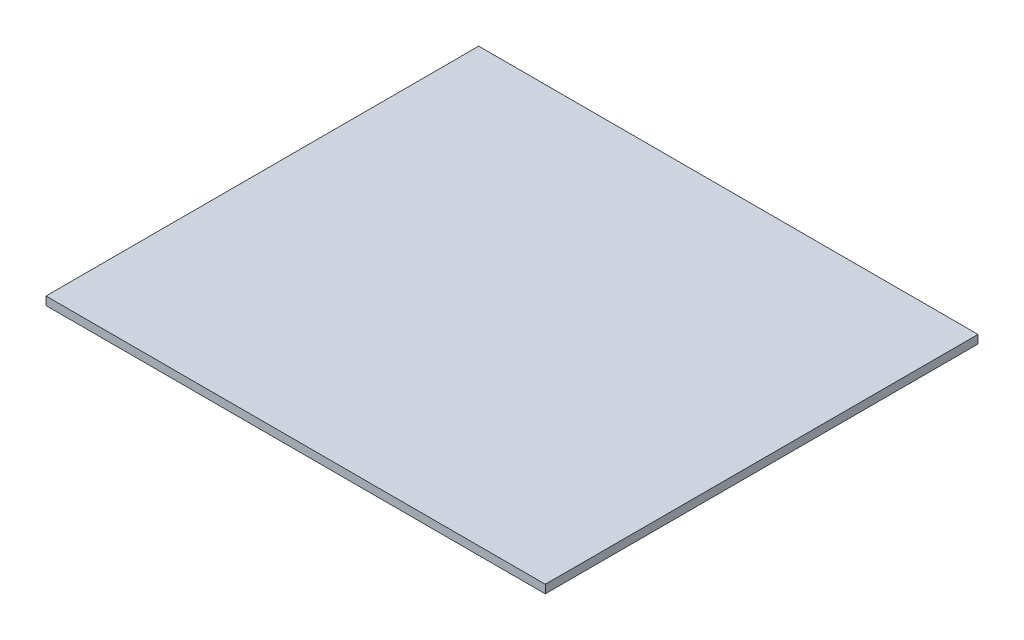
from build123d import *

# Parameters (mm, degrees)
SKETCH1_W           = 300
SKETCH1_H           = 260
BOSS_EXTRUDE1_DEPTH = 5


with BuildPart() as part:
    # Sketch1 → Boss-Extrude1 (new body)
    with BuildSketch(Plane(origin=(0, 0, 0), x_dir=(1, 0, 0), z_dir=(0, 1, 0))):
        Rectangle(SKETCH1_W, SKETCH1_H)
    extrude(amount=BOSS_EXTRUDE1_DEPTH)


solid = part.part
